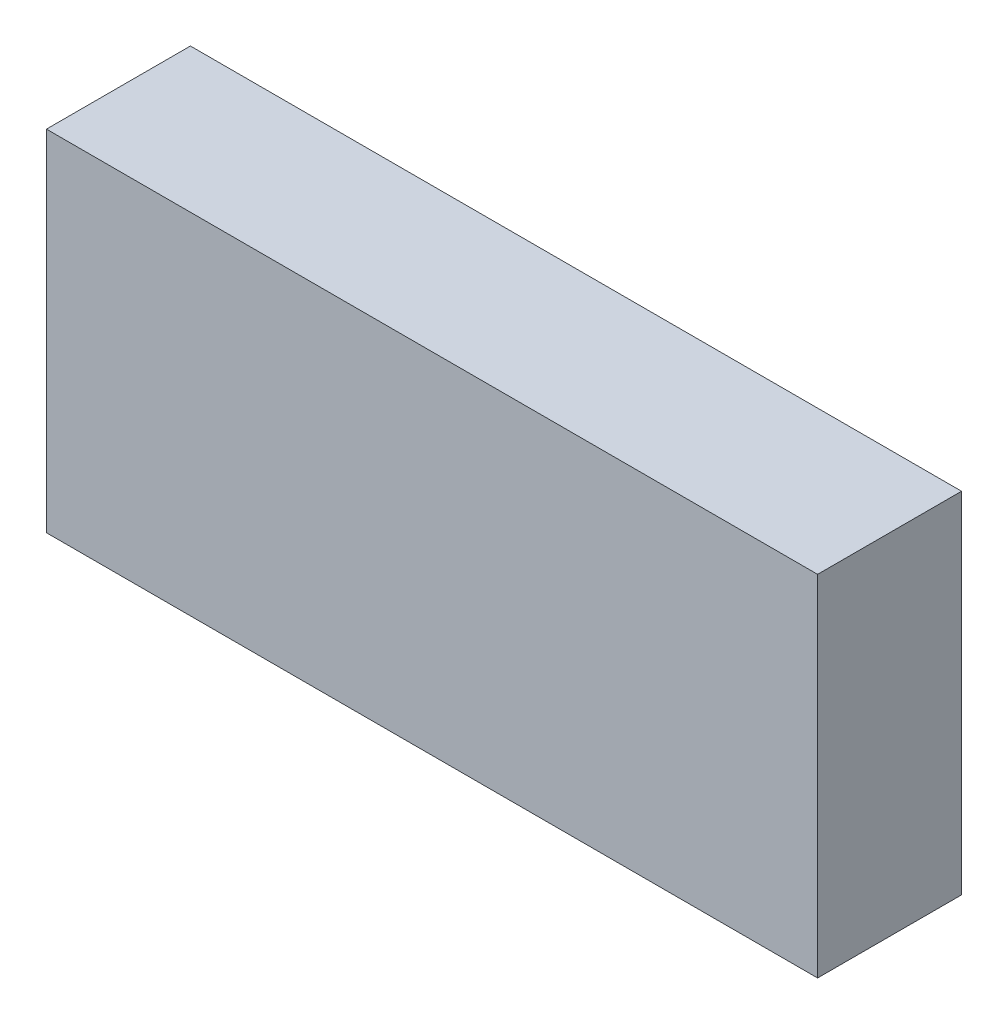
from build123d import *

# Parameters (mm, degrees)
SKETCH1_W           = 37.5
SKETCH1_H           = 17
BOSS_EXTRUDE1_DEPTH = 7


with BuildPart() as part:
    # Sketch1 → Boss-Extrude1 (new body)
    with BuildSketch(Plane.XY):
        with Locations((18.75, 8.5)):
            Rectangle(SKETCH1_W, SKETCH1_H)
    extrude(amount=BOSS_EXTRUDE1_DEPTH)


solid = part.part
